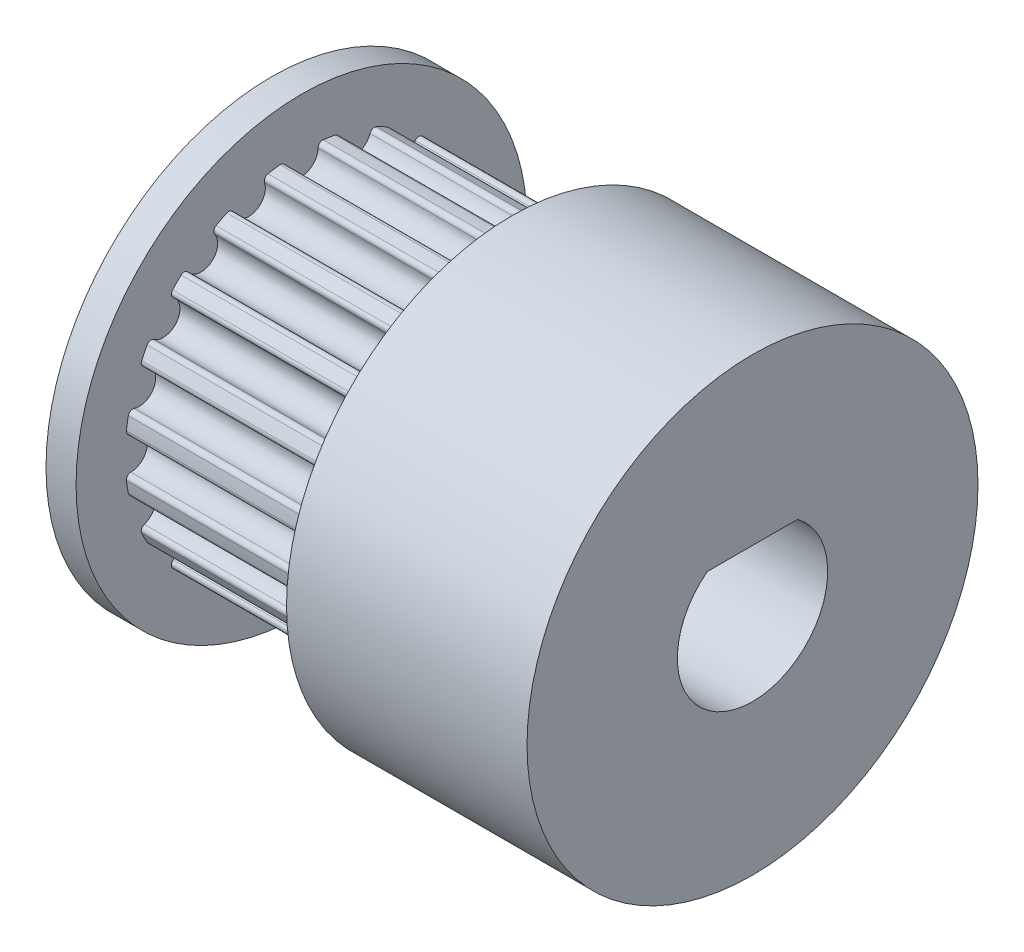
from build123d import *

# Parameters (mm, degrees)
SKETCH1_W                = 7
SKETCH1_H                = 7.5
CUT_EXTRUDE2_DEPTH       = 7
FILLET1_R                = 0.15
CIRPATTERN1_COUNT        = 20
FILLET1_OF_CIRPATTERN1_R = 0.15
CUT_EXTRUDE3_DEPTH       = 1
CUT_EXTRUDE3_DEPTH_BACK  = 17


with BuildPart() as part:
    # Sketch1 → Revolve1 (revolve)
    with BuildSketch(Plane.XY):
        Polygon((-7, 7.5), (-7, 0), (-16, 0), (-16, 7.5), (-15, 7.5), (-15, 5.87), (-8, 5.87), (-8, 7.5), align=None)
        with Locations((-3.5, 3.75)):
            Rectangle(SKETCH1_W, SKETCH1_H)
    revolve(axis=Axis((-7, 0, 0), (-1, 0, 0)))

    # Sketch3 → Cut-Extrude2 (cut)
    with BuildSketch(Plane.ZY.offset(8)):
        with BuildLine():
            ThreePointArc((0.524176814, 5.846549296), (0, 5.87), (-0.524176814, 5.846549296))
            ThreePointArc((-0.524176814, 5.846549296), (0, 5.13), (0.524176814, 5.846549296))
        make_face()
    cut_extrude2 = extrude(amount=CUT_EXTRUDE2_DEPTH, mode=Mode.SUBTRACT)

    # Fillet1
    fillet1_edges = [part.edges().sort_by_distance(p)[0] for p in [
        (-11.5, 5.846549296, -0.524176814),
        (-11.5, 5.846549296, 0.524176814),
    ]]
    fillet(fillet1_edges, radius=FILLET1_R)

    # CirPattern1: Cut-Extrude2 ×20 about axis
    cirpattern1_axis = Axis((0, 0, 0), (1, 0, 0))
    for i in range(1, CIRPATTERN1_COUNT):
        add(cut_extrude2.rotate(cirpattern1_axis, i * 360 / CIRPATTERN1_COUNT), mode=Mode.SUBTRACT)

    # Fillet1 of CirPattern1
    fillet1_of_cirpattern1_edges = [part.edges().sort_by_distance(p)[0] for p in [
        (-11.5, 5.722378349, 1.308161316),
        (-11.5, 5.398419262, 2.305204865),
        (-11.5, 5.038061139, 3.012447502),
        (-11.5, 4.421854338, 3.860583403),
        (-11.5, 3.860583403, 4.421854338),
        (-11.5, 3.012447502, 5.038061139),
        (-11.5, 2.305204865, 5.398419262),
        (-11.5, 1.308161316, 5.722378349),
        (-11.5, 0.524176814, 5.846549296),
        (-11.5, -0.524176814, 5.846549296),
        (-11.5, -1.308161316, 5.722378349),
        (-11.5, -2.305204865, 5.398419262),
        (-11.5, -3.012447502, 5.038061139),
        (-11.5, -3.860583403, 4.421854338),
        (-11.5, -4.421854338, 3.860583403),
        (-11.5, -5.038061139, 3.012447502),
        (-11.5, -5.398419262, 2.305204865),
        (-11.5, -5.722378349, 1.308161316),
        (-11.5, -5.846549296, 0.524176814),
        (-11.5, -5.846549296, -0.524176814),
        (-11.5, -5.722378349, -1.308161316),
        (-11.5, -5.398419262, -2.305204865),
        (-11.5, -5.038061139, -3.012447502),
        (-11.5, -4.421854338, -3.860583403),
        (-11.5, -3.860583403, -4.421854338),
        (-11.5, -3.012447502, -5.038061139),
        (-11.5, -2.305204865, -5.398419262),
        (-11.5, -1.308161316, -5.722378349),
        (-11.5, -0.524176814, -5.846549296),
        (-11.5, 0.524176814, -5.846549296),
        (-11.5, 1.308161316, -5.722378349),
        (-11.5, 2.305204865, -5.398419262),
        (-11.5, 3.012447502, -5.038061139),
        (-11.5, 3.860583403, -4.421854338),
        (-11.5, 4.421854338, -3.860583403),
        (-11.5, 5.038061139, -3.012447502),
        (-11.5, 5.398419262, -2.305204865),
        (-11.5, 5.722378349, -1.308161316),
    ]]
    fillet(fillet1_of_cirpattern1_edges, radius=FILLET1_OF_CIRPATTERN1_R)

    # Sketch2 → Cut-Extrude3 (cut, two sides)
    with BuildSketch(Plane.ZY.offset(16)) as cut_extrude3_sk:
        with BuildLine():
            Line((0, 2), (1.5, 2))
            ThreePointArc((1.5, 2), (0, -2.5), (-1.5, 2))
            Line((-1.5, 2), (0, 2))
        make_face()
    extrude(amount=CUT_EXTRUDE3_DEPTH, mode=Mode.SUBTRACT)
    extrude(cut_extrude3_sk.sketch, amount=-CUT_EXTRUDE3_DEPTH_BACK, mode=Mode.SUBTRACT)


solid = part.part
